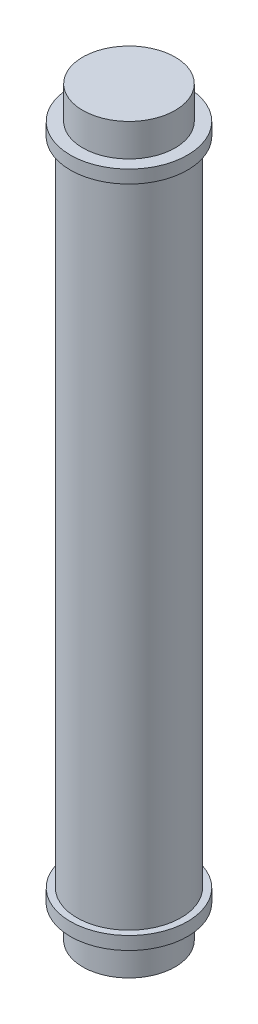
from build123d import *

# Parameters (mm, degrees)
SKETCH_1_R      = 2
SKETCH_1_R_2    = 1.5
EXTRUDE_1_DEPTH = 12.5
SKETCH_2_R      = 2.25
EXTRUDE_2_DEPTH = 0.5
SKETCH_3_R      = 1.775
EXTRUDE_3_DEPTH = 1.25


with BuildPart() as part:
    # 스케치1 → 보스-돌출1 (new body, symmetric)
    with BuildSketch(Plane(origin=(0, 0, 0), x_dir=(1, 0, 0), z_dir=(0, 1, 0))):
        Circle(SKETCH_1_R)
        Circle(SKETCH_1_R_2, mode=Mode.SUBTRACT)
    extrude(amount=EXTRUDE_1_DEPTH, both=True)

    # 스케치2 → 보스-돌출2 (add)
    with BuildSketch(Plane(origin=(0, 12.5, 0), x_dir=(1, 0, 0), z_dir=(0, 1, 0))):
        Circle(SKETCH_2_R)
    extrude_2 = extrude(amount=EXTRUDE_2_DEPTH)

    # 스케치3 → 보스-돌출3 (add)
    with BuildSketch(Plane(origin=(0, 13, 0), x_dir=(1, 0, 0), z_dir=(0, 1, 0))):
        Circle(SKETCH_3_R)
    extrude_3 = extrude(amount=EXTRUDE_3_DEPTH)

    # 대칭 복사1: 보스-돌출2, 보스-돌출3 across plane
    add(extrude_2.mirror(Plane.ZX))
    add(extrude_3.mirror(Plane.ZX))


solid = part.part
